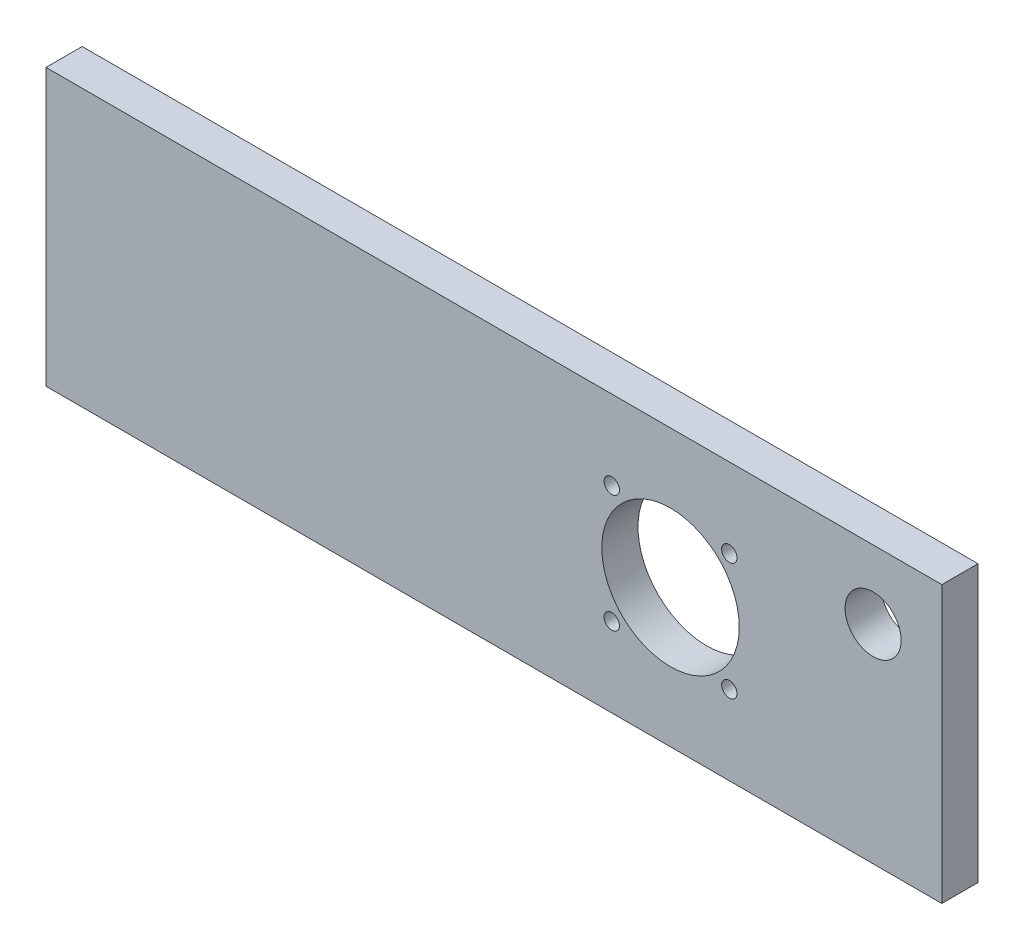
from build123d import *

# Parameters (mm, degrees)
SKETCH1_W           = 247.65
SKETCH1_H           = 76.3524
SKETCH1_R           = 19
SKETCH1_R_2         = 2.125
SKETCH1_R_3         = 7.75
BOSS_EXTRUDE1_DEPTH = 10


with BuildPart() as part:
    # Sketch1 → Boss-Extrude1 (new body)
    with BuildSketch(Plane.XY):
        with Locations((123.825, 38.1762)):
            Rectangle(SKETCH1_W, SKETCH1_H)
        with Locations((172.65, 38.1762)):
            Circle(SKETCH1_R, mode=Mode.SUBTRACT)
        with Locations((156.4, 54.4262)):
            Circle(SKETCH1_R_2, mode=Mode.SUBTRACT)
        with Locations((188.9, 54.4262)):
            Circle(SKETCH1_R_2, mode=Mode.SUBTRACT)
        with Locations((188.9, 21.9262)):
            Circle(SKETCH1_R_2, mode=Mode.SUBTRACT)
        with Locations((156.4, 21.9262)):
            Circle(SKETCH1_R_2, mode=Mode.SUBTRACT)
        with Locations((228.65, 57.3524)):
            Circle(SKETCH1_R_3, mode=Mode.SUBTRACT)
    extrude(amount=BOSS_EXTRUDE1_DEPTH)


solid = part.part
